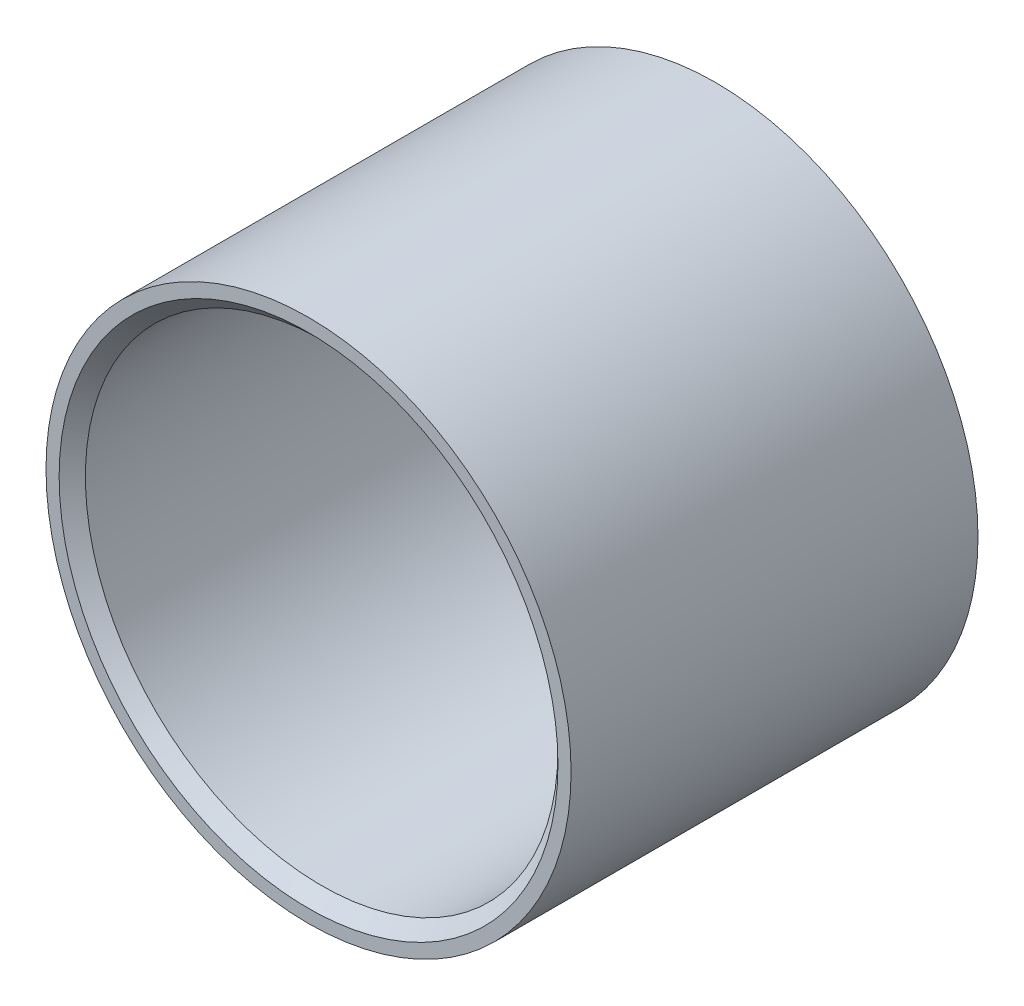
from build123d import *

# Parameters (mm, degrees)
SKETCH1_R           = 10
SKETCH1_R_2         = 9
BOSS_EXTRUDE1_DEPTH = 15.5
CHAMFER1_SIZE       = 0.5


with BuildPart() as part:
    # Sketch1 → Boss-Extrude1 (new body)
    with BuildSketch(Plane.XY):
        Circle(SKETCH1_R)
        Circle(SKETCH1_R_2, mode=Mode.SUBTRACT)
    extrude(amount=BOSS_EXTRUDE1_DEPTH)

    # Chamfer1
    chamfer1_edges = [part.edges().sort_by_distance(p)[0] for p in [
        (-9, 0, 0),
        (-9, 0, 15.5),
    ]]
    chamfer(chamfer1_edges, length=CHAMFER1_SIZE)


solid = part.part
